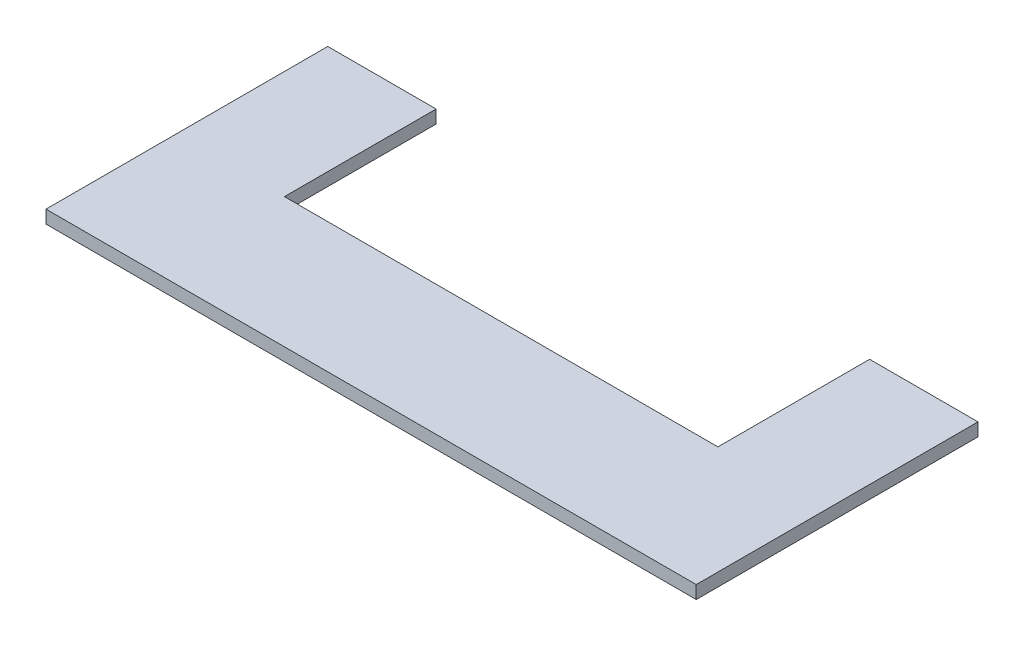
from build123d import *

# Parameters (mm, degrees)
BOSS_EXTRUDE1_DEPTH = 6


with BuildPart() as part:
    # Sketch1 → Boss-Extrude1 (new body)
    with BuildSketch(Plane(origin=(0, 0, 0), x_dir=(1, 0, 0), z_dir=(0, 1, 0))):
        Polygon((100, 65), (150, 65), (150, -65), (-150, -65), (-150, 65), (-100, 65), (-100, -5), (100, -5), align=None)
    extrude(amount=BOSS_EXTRUDE1_DEPTH)


solid = part.part
